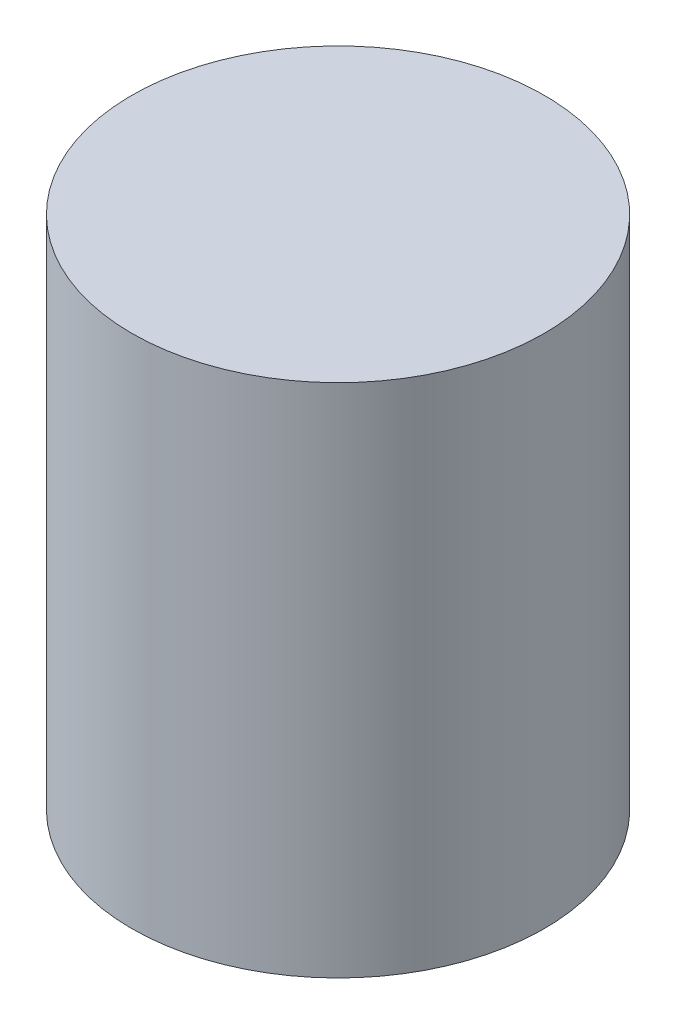
from build123d import *

# Parameters (mm, degrees)
SKETCH_1_R      = 8
EXTRUDE_1_DEPTH = 20


with BuildPart() as part:
    # 草图1 → 凸台-拉伸1 (new body)
    with BuildSketch(Plane(origin=(0, 0, 0), x_dir=(1, 0, 0), z_dir=(0, 1, 0))):
        Circle(SKETCH_1_R)
    extrude(amount=EXTRUDE_1_DEPTH)


solid = part.part
